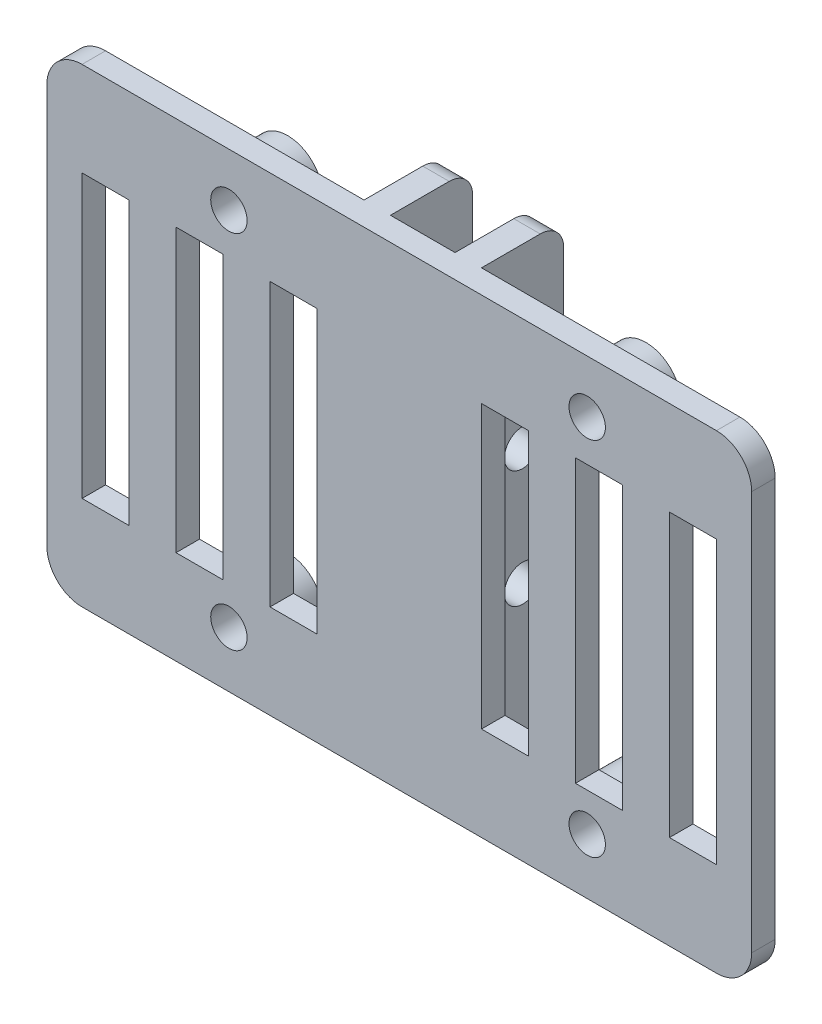
from build123d import *

# Parameters (mm, degrees)
ESQUISSE1_W                  = 60
ESQUISSE1_H                  = 40
BOSS_EXTRU_1_DEPTH           = 9
ESQUISSE2_W                  = 25
ESQUISSE2_H                  = 40
ESQUISSE2_W_2                = 5.5
ENL_V_MAT_EXTRU_1_DEPTH      = 7
ESQUISSE3_R                  = 1.55
ENL_V_MAT_EXTRU_2_DEPTH      = 36
CONG_1_R                     = 3
ESQUISSE9_R                  = 3
BOSS_EXTRU_2_DEPTH           = 3
ESQUISSE5_R                  = 1.55
ENL_V_MAT_EXTRU_4_DEPTH      = 8
ENL_V_MAT_EXTRU_4_DEPTH_BACK = 3
ESQUISSE8_W                  = 4
ESQUISSE8_H                  = 24
ENL_V_MAT_EXTRU_5_DEPTH      = 7
ESQUISSE6_W                  = 4
ESQUISSE6_H                  = 24
ENL_V_MAT_EXTRU_6_DEPTH      = 7
CONG_2_R                     = 2


with BuildPart() as part:
    # Esquisse1 → Boss.-Extru.1 (new body)
    with BuildSketch(Plane.XY):
        with Locations((30, 20)):
            Rectangle(ESQUISSE1_W, ESQUISSE1_H)
    extrude(amount=BOSS_EXTRU_1_DEPTH)

    # Esquisse2 → Enlèv. mat.-Extru.1 (cut)
    with BuildSketch(Plane(origin=(0, 0, 0), x_dir=(-1, 0, 0), z_dir=(0, 0, -1))):
        with Locations((-12.5, 20)):
            Rectangle(ESQUISSE2_W, ESQUISSE2_H)
        with Locations((-47.5, 20)):
            Rectangle(ESQUISSE2_W, ESQUISSE2_H)
        with Locations((-30, 20)):
            Rectangle(ESQUISSE2_W_2, ESQUISSE2_H)
    extrude(amount=-ENL_V_MAT_EXTRU_1_DEPTH, mode=Mode.SUBTRACT)

    # Esquisse3 → Enlèv. mat.-Extru.2 (cut, through all)
    with BuildSketch(Plane(origin=(35, 0, 0), x_dir=(0, 0, -1), z_dir=(1, 0, 0))):
        with Locations((-3.5, 15)):
            Circle(ESQUISSE3_R)
        with Locations((-3.5, 25)):
            Circle(ESQUISSE3_R)
    extrude(amount=-ENL_V_MAT_EXTRU_2_DEPTH, mode=Mode.SUBTRACT)

    # Congé1
    cong_1_edges = [part.edges().sort_by_distance(p)[0] for p in [
        (0, 40, 8),
        (60, 40, 8),
        (60, 0, 8),
        (0, 0, 8),
    ]]
    fillet(cong_1_edges, radius=CONG_1_R)

    # Esquisse9 → Boss.-Extru.2 (add)
    with BuildSketch(Plane(origin=(0, 0, 7), x_dir=(-1, 0, 0), z_dir=(0, 0, -1))):
        with Locations((-46, 35.5)):
            Circle(ESQUISSE9_R)
        with Locations((-15.5, 35.5)):
            Circle(ESQUISSE9_R)
        with Locations((-15.5, 4.75)):
            Circle(ESQUISSE9_R)
        with Locations((-46, 4.75)):
            Circle(ESQUISSE9_R)
    extrude(amount=BOSS_EXTRU_2_DEPTH)

    # Esquisse5 → Enlèv. mat.-Extru.4 (cut, two sides)
    with BuildSketch(Plane(origin=(0, 0, 7), x_dir=(-1, 0, 0), z_dir=(0, 0, -1))) as enl_v_mat_extru_4_sk:
        with Locations((-46, 35.5)):
            Circle(ESQUISSE5_R)
        with Locations((-46, 4.75)):
            Circle(ESQUISSE5_R)
        with Locations((-15.5, 4.75)):
            Circle(ESQUISSE5_R)
        with Locations((-15.5, 35.5)):
            Circle(ESQUISSE5_R)
    extrude(amount=ENL_V_MAT_EXTRU_4_DEPTH, mode=Mode.SUBTRACT)
    extrude(enl_v_mat_extru_4_sk.sketch, amount=-ENL_V_MAT_EXTRU_4_DEPTH_BACK, mode=Mode.SUBTRACT)

    # Esquisse8 → Enlèv. mat.-Extru.5 (cut)
    with BuildSketch(Plane(origin=(0, 0, 7), x_dir=(-1, 0, 0), z_dir=(0, 0, -1))):
        with Locations((-13, 20)):
            Rectangle(ESQUISSE8_W, ESQUISSE8_H)
        with Locations((-5, 20)):
            Rectangle(ESQUISSE8_W, ESQUISSE8_H)
        with Locations((-21, 20)):
            Rectangle(ESQUISSE8_W, ESQUISSE8_H)
    extrude(amount=-ENL_V_MAT_EXTRU_5_DEPTH, mode=Mode.SUBTRACT)

    # Esquisse6 → Enlèv. mat.-Extru.6 (cut)
    with BuildSketch(Plane(origin=(0, 0, 7), x_dir=(-1, 0, 0), z_dir=(0, 0, -1))):
        with Locations((-47, 20)):
            Rectangle(ESQUISSE6_W, ESQUISSE6_H)
        with Locations((-55, 20)):
            Rectangle(ESQUISSE6_W, ESQUISSE6_H)
        with Locations((-39, 20)):
            Rectangle(ESQUISSE6_W, ESQUISSE6_H)
    extrude(amount=-ENL_V_MAT_EXTRU_6_DEPTH, mode=Mode.SUBTRACT)

    # Congé2
    cong_2_edges = [part.edges().sort_by_distance(p)[0] for p in [
        (33.875, 40, 0),
        (26.125, 40, 0),
        (26.125, 0, 0),
        (33.875, 0, 0),
    ]]
    fillet(cong_2_edges, radius=CONG_2_R)


solid = part.part
